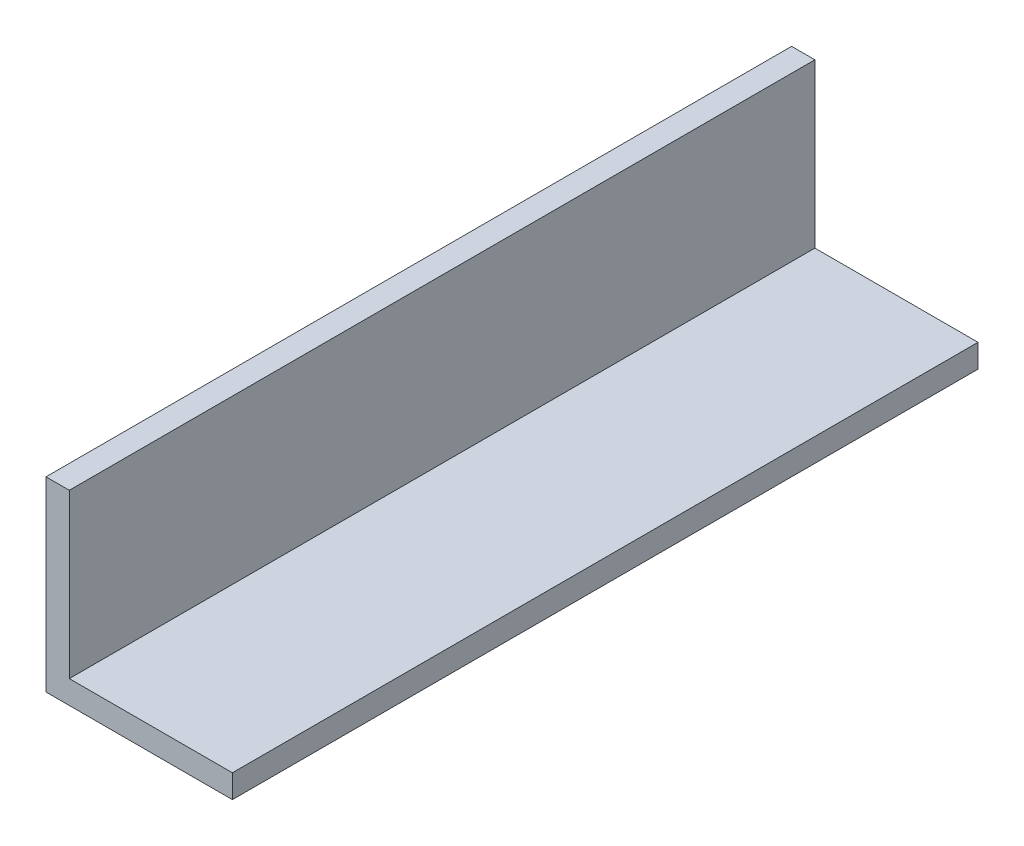
from build123d import *

# Parameters (mm, degrees)
BOSS_EXTRUDE1_DEPTH = 50.8


with BuildPart() as part:
    # Sketch1 → Boss-Extrude1 (new body, symmetric)
    with BuildSketch(Plane.XY):
        Polygon((0, 25.4), (0, 0), (25.4, 0), (25.4, 3.175), (3.175, 3.175), (3.175, 25.4), align=None)
    extrude(amount=BOSS_EXTRUDE1_DEPTH, both=True)


solid = part.part
